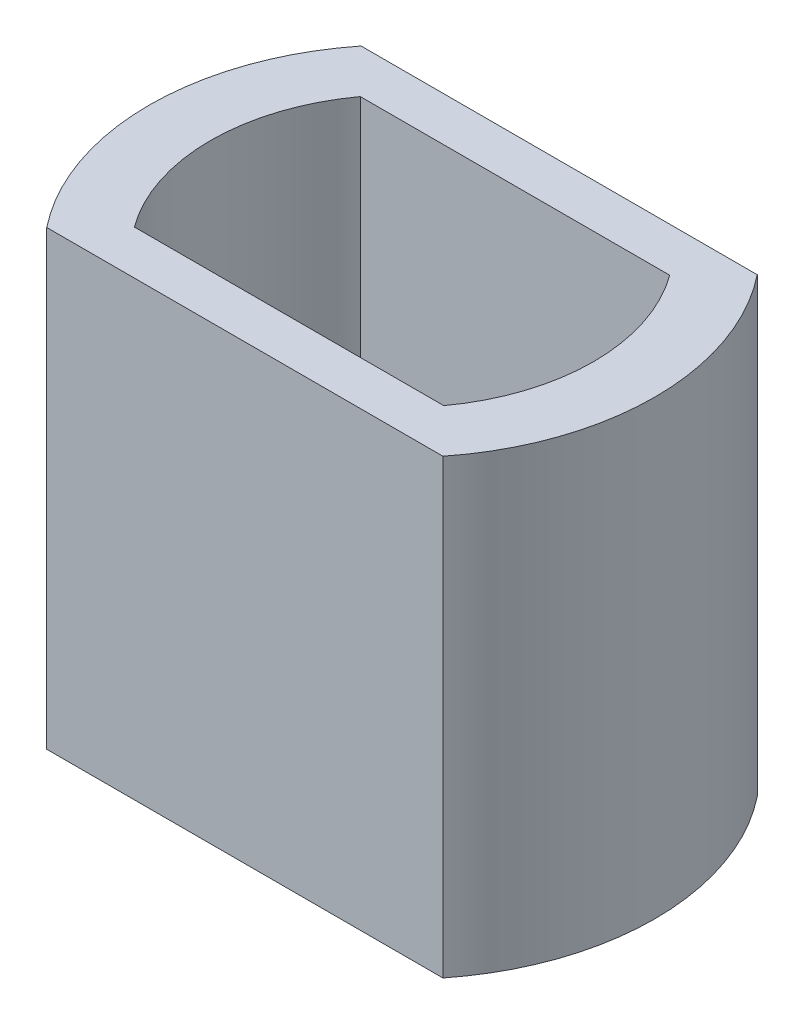
from build123d import *

# Parameters (mm, degrees)
BOSS_EXTRUDE1_DEPTH = 5.842


with BuildPart() as part:
    # Sketch1 → Boss-Extrude1 (new body)
    with BuildSketch(Plane(origin=(0, 0, 0), x_dir=(1, 0, 0), z_dir=(0, 1, 0))):
        with BuildLine():
            Line((-2.4765, -2.032), (2.4765, -2.032))
            Line((2.4765, -2.032), (2.560704247, -2.032))
            ThreePointArc((2.560704247, -2.032), (3.26898, 0), (2.560704247, 2.032))
            Line((2.560704247, 2.032), (2.419800194, 2.032))
            Line((2.419800194, 2.032), (-2.533199806, 2.032))
            Line((-2.533199806, 2.032), (-2.560704247, 2.032))
            ThreePointArc((-2.560704247, 2.032), (-3.26898, 0), (-2.560704247, -2.032))
            Line((-2.560704247, -2.032), (-2.4765, -2.032))
        make_face()
        with BuildLine():
            Line((1.999998, -1.4605), (-1.999998, -1.4605))
            ThreePointArc((-1.999998, -1.4605), (-2.4765, 0), (-1.999998, 1.4605))
            Line((-1.999998, 1.4605), (1.999998, 1.4605))
            ThreePointArc((1.999998, 1.4605), (2.4765, 0), (1.999998, -1.4605))
        make_face(mode=Mode.SUBTRACT)
    extrude(amount=BOSS_EXTRUDE1_DEPTH)


solid = part.part
